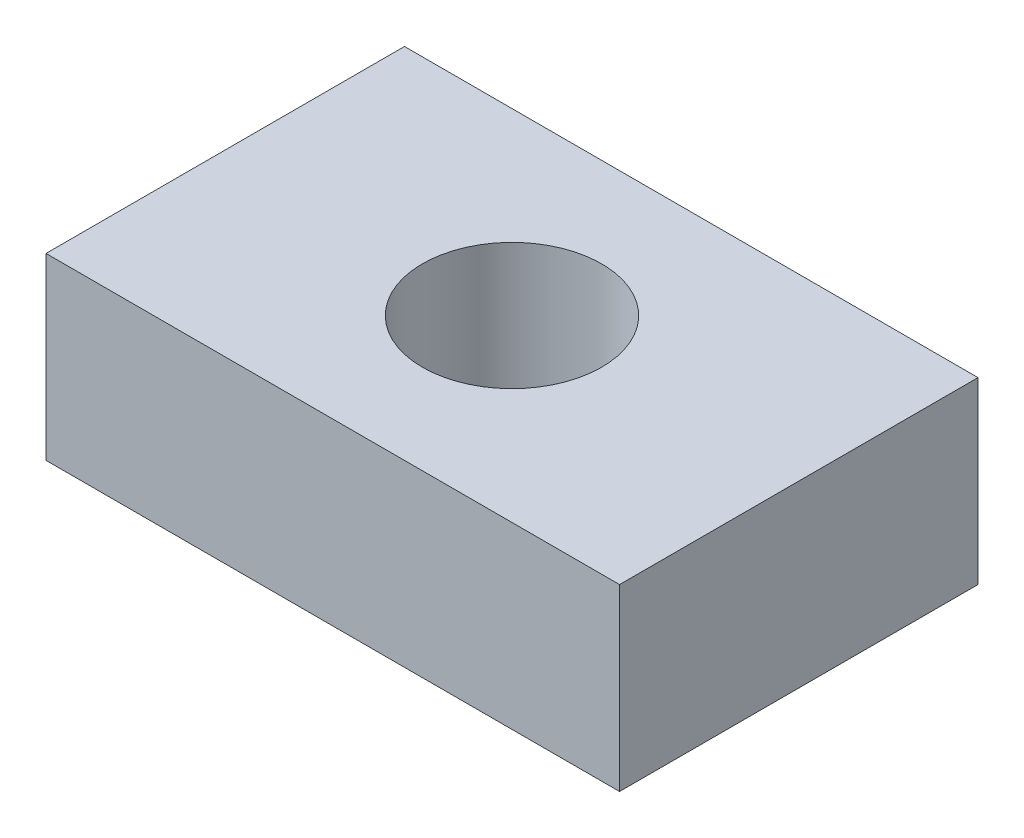
from build123d import *

# Parameters (mm, degrees)
SKETCH1_W           = 160
SKETCH1_H           = 100
SKETCH1_R           = 25
BOSS_EXTRUDE1_DEPTH = 50


with BuildPart() as part:
    # Sketch1 → Boss-Extrude1 (new body)
    with BuildSketch(Plane(origin=(0, 0, 0), x_dir=(1, 0, 0), z_dir=(0, 1, 0))):
        Rectangle(SKETCH1_W, SKETCH1_H)
        Circle(SKETCH1_R, mode=Mode.SUBTRACT)
    extrude(amount=BOSS_EXTRUDE1_DEPTH)


solid = part.part
